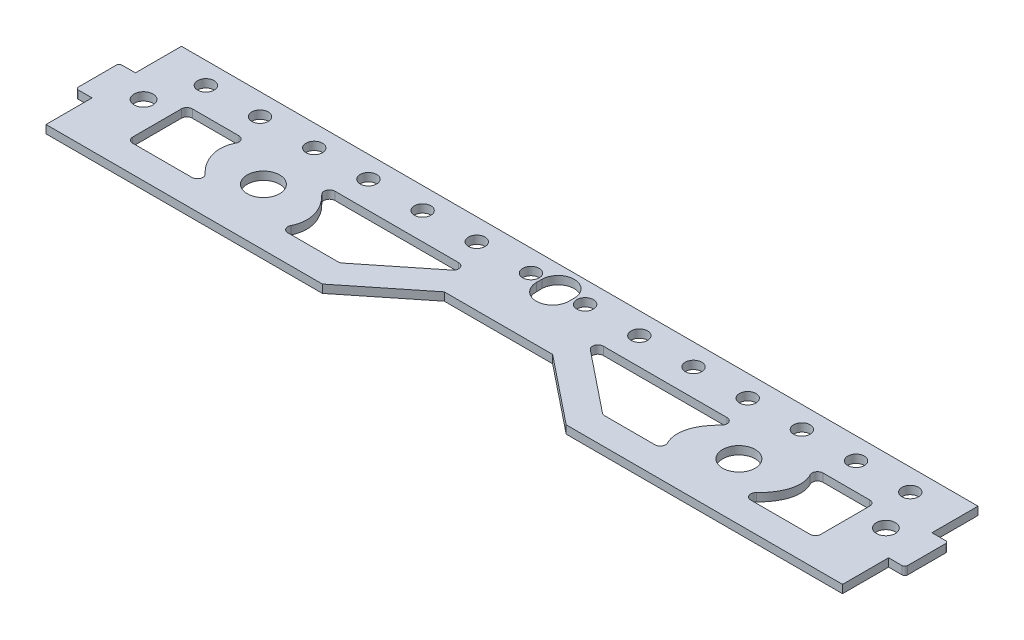
from build123d import *

# Parameters (mm, degrees)
SKETCH_1_W          = 147
SKETCH_1_H          = 25
EXTRUDE_1_DEPTH     = 1.5
CUT_EXTRUDE_1_DEPTH = 2.5
SKETCH_4_W          = 10
SKETCH_4_H          = 25
EXTRUDE_2_DEPTH     = 1.5
SKETCH_5_R          = 1.75
CUT_EXTRUDE_3_DEPTH = 2.5
CUT_EXTRUDE_4_DEPTH = 2.5
SKETCH_7_W          = 3
SKETCH_7_H          = 8
EXTRUDE_3_DEPTH     = 1.5
FILLET_4_R          = 0.5
SKETCH_8_R          = 1.525
CUT_EXTRUDE_5_DEPTH = 10
SKETCH_9_R          = 3
CUT_EXTRUDE_6_DEPTH = 10
FILLET_5_R          = 1


with BuildPart() as part:
    # 草图1 → 凸台-拉伸1 (new body)
    with BuildSketch(Plane(origin=(0, 0, 0), x_dir=(1, 0, 0), z_dir=(0, 1, 0))):
        Rectangle(SKETCH_1_W, SKETCH_1_H)
    extrude(amount=EXTRUDE_1_DEPTH)

    # 草图2 → 切除-拉伸1 (cut, through all)
    with BuildSketch(Plane.XZ):
        Polygon((10, 2.5), (-10, 2.5), (-22.5, 12.5), (22.5, 12.5), align=None)
    extrude(amount=-CUT_EXTRUDE_1_DEPTH, mode=Mode.SUBTRACT)

    # 草图4 → 凸台-拉伸2 (add)
    with BuildSketch(Plane(origin=(0, 1.5, 0), x_dir=(1, 0, 0), z_dir=(0, 1, 0))):
        with Locations((68.5, 0)):
            Rectangle(SKETCH_4_W, SKETCH_4_H)
    extrude_2 = extrude(amount=-EXTRUDE_2_DEPTH)

    # 镜向4: 凸台-拉伸2 across plane
    add(extrude_2.mirror(Plane(origin=(0, 0, 0), x_dir=(0, 0, 1), z_dir=(1, 0, 0))))

    # 草图5 → 切除-拉伸3 (cut, through all)
    with BuildSketch(Plane.XZ):
        with Locations((-68.5, -0.5)):
            Circle(SKETCH_5_R)
        with Locations((68.5, -0.5)):
            Circle(SKETCH_5_R)
    extrude(amount=-CUT_EXTRUDE_3_DEPTH, mode=Mode.SUBTRACT)

    # 草图6 → 切除-拉伸4 (cut, through all)
    with BuildSketch(Plane(origin=(0, 1.5, 0), x_dir=(1, 0, 0), z_dir=(0, 1, 0))):
        with BuildLine():
            Line((3, 8.5), (3, 7.5))
            ThreePointArc((3, 7.5), (0, 4.5), (-3, 7.5))
            Line((-3, 7.5), (-3, 8.5))
            ThreePointArc((-3, 8.5), (0, 11.5), (3, 8.5))
        make_face()
    extrude(amount=-CUT_EXTRUDE_4_DEPTH, mode=Mode.SUBTRACT)

    # 草图7 → 凸台-拉伸3 (add)
    with BuildSketch(Plane(origin=(0, 1.5, 0), x_dir=(1, 0, 0), z_dir=(0, 1, 0))):
        with Locations((-75, 0)):
            Rectangle(SKETCH_7_W, SKETCH_7_H)
        with Locations((75, 0)):
            Rectangle(SKETCH_7_W, SKETCH_7_H)
    extrude(amount=-EXTRUDE_3_DEPTH)

    # 圆角4
    fillet_4_edges = [part.edges().sort_by_distance(p)[0] for p in [
        (-76.5, 0.75, 4),
        (-76.5, 0.75, -4),
        (76.5, 0.75, -4),
        (76.5, 0.75, 4),
    ]]
    fillet(fillet_4_edges, radius=FILLET_4_R)

    # 草图8 → 切除-拉伸5 (cut)
    with BuildSketch(Plane.XZ):
        with Locations((25, -8.5)):
            Circle(SKETCH_8_R)
        with Locations((65, -8.5)):
            Circle(SKETCH_8_R)
        with Locations((35, -8.5)):
            Circle(SKETCH_8_R)
        with Locations((45, -8.5)):
            Circle(SKETCH_8_R)
        with Locations((15, -8.5)):
            Circle(SKETCH_8_R)
        with Locations((5, -8.5)):
            Circle(SKETCH_8_R)
        with Locations((-5, -8.5)):
            Circle(SKETCH_8_R)
        with Locations((-15, -8.5)):
            Circle(SKETCH_8_R)
        with Locations((-25, -8.5)):
            Circle(SKETCH_8_R)
        with Locations((-35, -8.5)):
            Circle(SKETCH_8_R)
        with Locations((-45, -8.5)):
            Circle(SKETCH_8_R)
        with Locations((-55, -8.5)):
            Circle(SKETCH_8_R)
        with Locations((55, -8.5)):
            Circle(SKETCH_8_R)
        with Locations((-65, -8.5)):
            Circle(SKETCH_8_R)
    extrude(amount=-CUT_EXTRUDE_5_DEPTH, mode=Mode.SUBTRACT)

    # 草图9 → 切除-拉伸6 (cut)
    with BuildSketch(Plane.XZ):
        with BuildLine():
            Line((-24.253905297, 7.5), (-35.905526527, 7.5))
            add(Edge.make_bspline(
                [(-34.480026441, 5.420201433), (-34.911161472, 6.604735198), (-35.905526527, 7.5)],
                knots=[0, 0, 0, 0.356339332, 0.356339332, 0.356339332], degree=2, weights=[1, 0.984169729, 1]))
            add(Edge.make_bspline(
                [(-39.185779079, -3.5), (-32.630899612, 0.339767225), (-34.480026441, 5.420201433)],
                knots=[4.967874336, 4.967874336, 4.967874336, 6.283185307, 6.283185307, 6.283185307], degree=2, weights=[1, 0.79142752, 1]))
            Line((-39.185779079, -3.5), (-10.503905297, -3.5))
            Line((-10.503905297, -3.5), (-24.253905297, 7.5))
        make_face()
        with BuildLine():
            Line((-48.568126218, 7.5), (-63.5, 7.5))
            Line((-63.5, 7.5), (-63.5, -3.5))
            Line((-63.5, -3.5), (-51.84837877, -3.5))
            add(Edge.make_bspline(
                [(-48.568126218, 7.5), (-57.957194606, 2), (-51.84837877, -3.5)],
                knots=[1.826281682, 1.826281682, 1.826281682, 3.497931985, 3.497931985, 3.497931985], degree=2, weights=[1, 0.670565772, 1]))
        make_face()
        with Locations((-43.876952648, 2)):
            Circle(SKETCH_9_R)
    cut_extrude_6 = extrude(amount=-CUT_EXTRUDE_6_DEPTH, mode=Mode.SUBTRACT)

    # 镜向5: 切除-拉伸6 across plane
    add(cut_extrude_6.mirror(Plane(origin=(0, 0, 0), x_dir=(0, 0, 1), z_dir=(1, 0, 0))), mode=Mode.SUBTRACT)

    # 圆角5
    fillet_5_edges = [part.edges().sort_by_distance(p)[0] for p in [
        (39.185779079, 0.75, -3.5),
        (51.84837877, 0.75, -3.5),
        (10.503905297, 0.75, -3.5),
        (24.253905297, 0.75, 7.5),
        (35.905526527, 0.75, 7.5),
        (48.568126218, 0.75, 7.5),
        (-24.253905297, 0.75, 7.5),
        (-10.503905297, 0.75, -3.5),
        (-39.185779079, 0.75, -3.5),
        (-51.84837877, 0.75, -3.5),
        (-35.905526527, 0.75, 7.5),
        (-48.568126218, 0.75, 7.5),
        (-63.5, 0.75, -3.5),
        (63.5, 0.75, 7.5),
        (63.5, 0.75, -3.5),
        (-63.5, 0.75, 7.5),
    ]]
    fillet(fillet_5_edges, radius=FILLET_5_R)


solid = part.part
